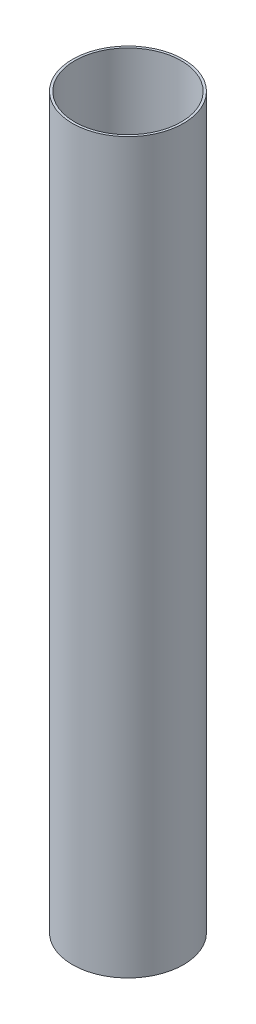
from build123d import *

# Parameters (mm, degrees)
SKETCH1_R           = 38.1
SKETCH1_R_2         = 36.5
BOSS_EXTRUDE1_DEPTH = 500


with BuildPart() as part:
    # Sketch1 → Boss-Extrude1 (new body)
    with BuildSketch(Plane(origin=(0, 0, 0), x_dir=(1, 0, 0), z_dir=(0, 1, 0))):
        Circle(SKETCH1_R)
        Circle(SKETCH1_R_2, mode=Mode.SUBTRACT)
    extrude(amount=BOSS_EXTRUDE1_DEPTH)


solid = part.part
